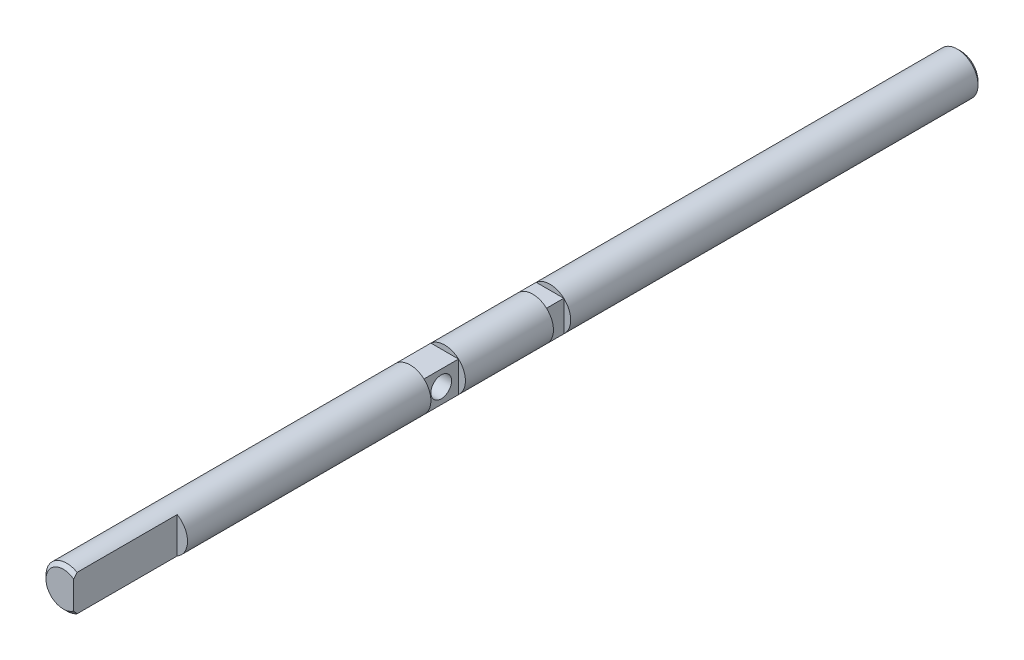
from build123d import *

# Parameters (mm, degrees)
SKETCH1_R               = 6
BOSS_EXTRUDE1_DEPTH     = 260
CHAMFER1_SIZE           = 1
SKETCH3_W               = 3
SKETCH3_H               = 30
SKETCH3_W_2             = 2
SKETCH3_H_2             = 10
SKETCH3_H_3             = 5
CUT_EXTRUDE1_DEPTH      = 7
CUT_EXTRUDE1_DEPTH_BACK = 7
SKETCH4_R               = 3
CUT_EXTRUDE2_DEPTH      = 3
CUT_EXTRUDE2_DEPTH_BACK = 11
SKETCH5_W               = 10
SKETCH5_H               = 1.527864045
SKETCH5_W_2             = 5
CUT_EXTRUDE3_DEPTH      = 7
CUT_EXTRUDE3_DEPTH_BACK = 7


with BuildPart() as part:
    # Sketch1 → Boss-Extrude1 (new body)
    with BuildSketch(Plane.XY):
        Circle(SKETCH1_R)
    extrude(amount=BOSS_EXTRUDE1_DEPTH)

    # Chamfer1
    chamfer1_edges = [part.edges().sort_by_distance(p)[0] for p in [
        (-6, 0, 0),
        (-6, 0, 260),
    ]]
    chamfer(chamfer1_edges, length=CHAMFER1_SIZE)

    # Sketch3 → Cut-Extrude1 (cut, two sides)
    with BuildSketch(Plane(origin=(0, 0, 0), x_dir=(1, 0, 0), z_dir=(0, 1, 0))) as cut_extrude1_sk:
        with Locations((4.5, -245)):
            Rectangle(SKETCH3_W, SKETCH3_H)
        with Locations((5, -154.5)):
            Rectangle(SKETCH3_W_2, SKETCH3_H_2)
        with Locations((-5, -154.5)):
            Rectangle(SKETCH3_W_2, SKETCH3_H_2)
        with Locations((5, -121.5)):
            Rectangle(SKETCH3_W_2, SKETCH3_H_3)
    extrude(amount=CUT_EXTRUDE1_DEPTH, mode=Mode.SUBTRACT)
    extrude(cut_extrude1_sk.sketch, amount=-CUT_EXTRUDE1_DEPTH_BACK, mode=Mode.SUBTRACT)

    # Sketch4 → Cut-Extrude2 (cut, two sides)
    with BuildSketch(Plane(origin=(4, 0, 0), x_dir=(0, 0, -1), z_dir=(1, 0, 0))) as cut_extrude2_sk:
        with Locations((-154.5, 0)):
            Circle(SKETCH4_R)
    extrude(amount=CUT_EXTRUDE2_DEPTH, mode=Mode.SUBTRACT)
    extrude(cut_extrude2_sk.sketch, amount=-CUT_EXTRUDE2_DEPTH_BACK, mode=Mode.SUBTRACT)

    # Sketch5 → Cut-Extrude3 (cut, two sides)
    with BuildSketch(Plane(origin=(0, 0, 0), x_dir=(0, 0, -1), z_dir=(1, 0, 0))) as cut_extrude3_sk:
        with Locations((-154.5, 5.236067978)):
            Rectangle(SKETCH5_W, SKETCH5_H)
        with Locations((-121.5, 5.236067978)):
            Rectangle(SKETCH5_W_2, SKETCH5_H)
    extrude(amount=CUT_EXTRUDE3_DEPTH, mode=Mode.SUBTRACT)
    extrude(cut_extrude3_sk.sketch, amount=-CUT_EXTRUDE3_DEPTH_BACK, mode=Mode.SUBTRACT)


solid = part.part
